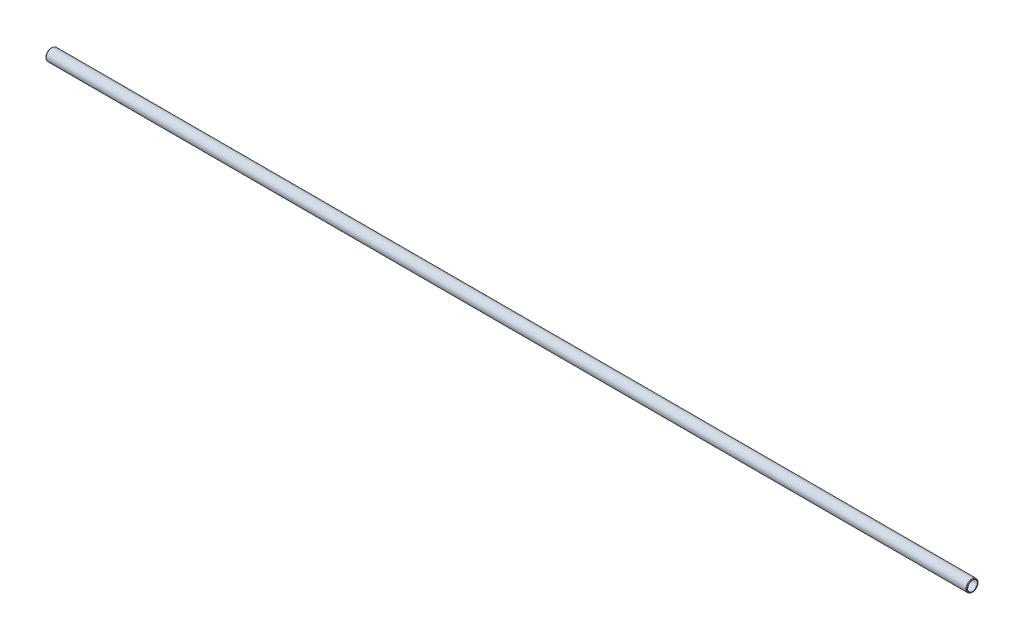
from build123d import *


with BuildPart() as part:
    # Sketch1 → Revolve1 (revolve)
    with BuildSketch(Plane.XY):
        with BuildLine():
            Line((-0.396407684, 5.304957684), (-0.254, 5.16255))
            Line((-0.254, 5.16255), (0, 5.16255))
            Line((0, 5.16255), (0.508, 5.67055))
            Line((0.508, 5.67055), (958.85, 5.67055))
            Line((958.85, 5.67055), (959.358, 5.16255))
            Line((959.358, 5.16255), (959.612, 5.16255))
            Line((959.612, 5.16255), (959.754407684, 5.304957684))
            ThreePointArc((959.754407684, 5.304957684), (959.791605122, 5.394760245), (959.754407684, 5.484562806))
            Line((959.754407684, 5.484562806), (959.221910245, 6.017060245))
            ThreePointArc((959.221910245, 6.017060245), (959.057103184, 6.127180803), (958.8627, 6.16585))
            Line((958.8627, 6.16585), (0.4953, 6.16585))
            ThreePointArc((0.4953, 6.16585), (0.300896816, 6.127180803), (0.136089755, 6.017060245))
            Line((0.136089755, 6.017060245), (-0.396407684, 5.484562806))
            ThreePointArc((-0.396407684, 5.484562806), (-0.433605122, 5.394760245), (-0.396407684, 5.304957684))
        make_face()
    revolve(axis=Axis((959.358, 0, 0), (-1, 0, 0)))


solid = part.part
